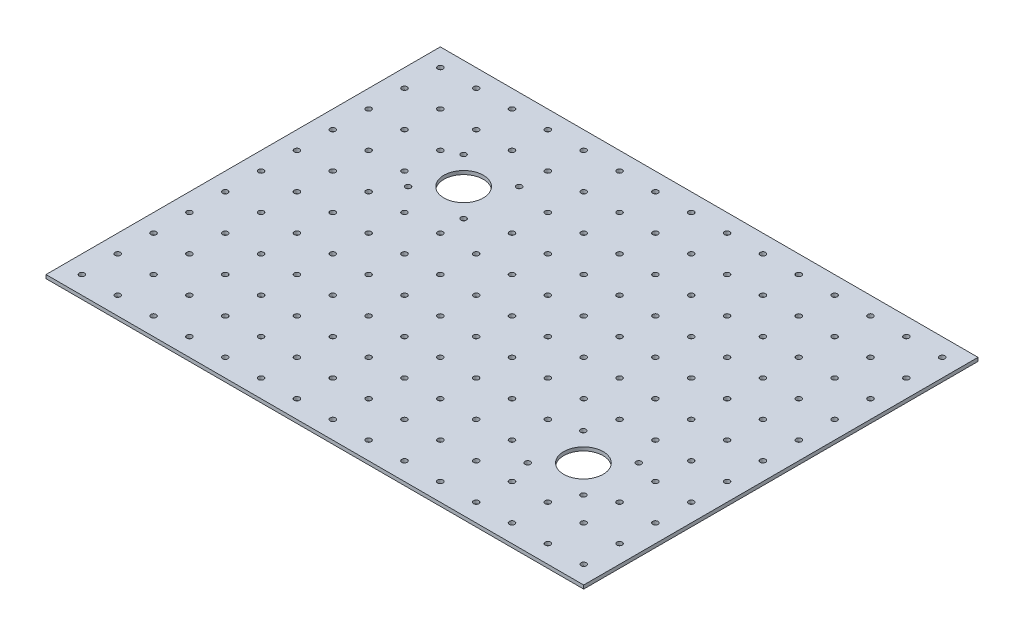
from build123d import *

# Parameters (mm, degrees)
SKETCH1_W           = 220
SKETCH1_H           = 2
BOSS_EXTRUDE1_DEPTH = 300
SKETCH2_R           = 11
SKETCH2_R_2         = 1.5
CUT_EXTRUDE1_DEPTH  = 10


with BuildPart() as part:
    # Sketch1 → Boss-Extrude1 (new body)
    with BuildSketch(Plane(origin=(0, 0, 0), x_dir=(0, 0, -1), z_dir=(1, 0, 0))):
        with Locations((83.3216851, 1)):
            Rectangle(SKETCH1_W, SKETCH1_H)
    extrude(amount=BOSS_EXTRUDE1_DEPTH)

    # Sketch2 → Cut-Extrude1 (cut)
    with BuildSketch(Plane(origin=(0, 2, 0), x_dir=(1, 0, 0), z_dir=(0, 1, 0))):
        with Locations((74, 132.3216851)):
            Circle(SKETCH2_R)
        with Locations((89.5, 116.8216851)):
            Circle(SKETCH2_R_2)
        with Locations((58.5, 116.8216851)):
            Circle(SKETCH2_R_2)
        with Locations((89.5, 147.8216851)):
            Circle(SKETCH2_R_2)
        with Locations((58.5, 147.8216851)):
            Circle(SKETCH2_R_2)
        with Locations((256.33130124, 47.719426297)):
            Circle(SKETCH2_R_2)
        with Locations((256.457517214, 16.719426297)):
            Circle(SKETCH2_R_2)
        with Locations((225.33130124, 16.719426297)):
            Circle(SKETCH2_R_2)
        with Locations((225.33130124, 47.719426297)):
            Circle(SKETCH2_R_2)
        with Locations((240.957517214, 32.219426297)):
            Circle(SKETCH2_R)
        with Locations((10, -16.6783149)):
            Circle(SKETCH2_R_2)
        with Locations((10, 3.3216851)):
            Circle(SKETCH2_R_2)
        with Locations((10, 23.3216851)):
            Circle(SKETCH2_R_2)
        with Locations((10, 63.3216851)):
            Circle(SKETCH2_R_2)
        with Locations((10, 43.3216851)):
            Circle(SKETCH2_R_2)
        with Locations((10, 143.3216851)):
            Circle(SKETCH2_R_2)
        with Locations((10, 123.3216851)):
            Circle(SKETCH2_R_2)
        with Locations((10, 103.3216851)):
            Circle(SKETCH2_R_2)
        with Locations((10, 83.3216851)):
            Circle(SKETCH2_R_2)
        with Locations((10, 183.3216851)):
            Circle(SKETCH2_R_2)
        with Locations((10, 163.3216851)):
            Circle(SKETCH2_R_2)
        with Locations((30, -16.6783149)):
            Circle(SKETCH2_R_2)
        with Locations((30, 3.3216851)):
            Circle(SKETCH2_R_2)
        with Locations((30, 23.3216851)):
            Circle(SKETCH2_R_2)
        with Locations((30, 43.3216851)):
            Circle(SKETCH2_R_2)
        with Locations((30, 63.3216851)):
            Circle(SKETCH2_R_2)
        with Locations((30, 83.3216851)):
            Circle(SKETCH2_R_2)
        with Locations((30, 103.3216851)):
            Circle(SKETCH2_R_2)
        with Locations((30, 123.3216851)):
            Circle(SKETCH2_R_2)
        with Locations((30, 143.3216851)):
            Circle(SKETCH2_R_2)
        with Locations((30, 163.3216851)):
            Circle(SKETCH2_R_2)
        with Locations((30, 183.3216851)):
            Circle(SKETCH2_R_2)
        with Locations((50, -16.6783149)):
            Circle(SKETCH2_R_2)
        with Locations((50, 3.3216851)):
            Circle(SKETCH2_R_2)
        with Locations((50, 23.3216851)):
            Circle(SKETCH2_R_2)
        with Locations((50, 43.3216851)):
            Circle(SKETCH2_R_2)
        with Locations((50, 63.3216851)):
            Circle(SKETCH2_R_2)
        with Locations((50, 83.3216851)):
            Circle(SKETCH2_R_2)
        with Locations((50, 103.3216851)):
            Circle(SKETCH2_R_2)
        with Locations((50, 123.3216851)):
            Circle(SKETCH2_R_2)
        with Locations((50, 143.3216851)):
            Circle(SKETCH2_R_2)
        with Locations((50, 163.3216851)):
            Circle(SKETCH2_R_2)
        with Locations((50, 183.3216851)):
            Circle(SKETCH2_R_2)
        with Locations((70, -16.6783149)):
            Circle(SKETCH2_R_2)
        with Locations((70, 3.3216851)):
            Circle(SKETCH2_R_2)
        with Locations((70, 23.3216851)):
            Circle(SKETCH2_R_2)
        with Locations((70, 43.3216851)):
            Circle(SKETCH2_R_2)
        with Locations((70, 63.3216851)):
            Circle(SKETCH2_R_2)
        with Locations((70, 83.3216851)):
            Circle(SKETCH2_R_2)
        with Locations((70, 103.3216851)):
            Circle(SKETCH2_R_2)
        with Locations((70, 163.3216851)):
            Circle(SKETCH2_R_2)
        with Locations((70, 183.3216851)):
            Circle(SKETCH2_R_2)
        with Locations((90, -16.6783149)):
            Circle(SKETCH2_R_2)
        with Locations((90, 3.3216851)):
            Circle(SKETCH2_R_2)
        with Locations((90, 23.3216851)):
            Circle(SKETCH2_R_2)
        with Locations((90, 43.3216851)):
            Circle(SKETCH2_R_2)
        with Locations((90, 63.3216851)):
            Circle(SKETCH2_R_2)
        with Locations((90, 83.3216851)):
            Circle(SKETCH2_R_2)
        with Locations((90, 103.3216851)):
            Circle(SKETCH2_R_2)
        with Locations((90, 163.3216851)):
            Circle(SKETCH2_R_2)
        with Locations((90, 183.3216851)):
            Circle(SKETCH2_R_2)
        with Locations((110, -16.6783149)):
            Circle(SKETCH2_R_2)
        with Locations((110, 3.3216851)):
            Circle(SKETCH2_R_2)
        with Locations((110, 23.3216851)):
            Circle(SKETCH2_R_2)
        with Locations((110, 43.3216851)):
            Circle(SKETCH2_R_2)
        with Locations((110, 63.3216851)):
            Circle(SKETCH2_R_2)
        with Locations((110, 83.3216851)):
            Circle(SKETCH2_R_2)
        with Locations((110, 103.3216851)):
            Circle(SKETCH2_R_2)
        with Locations((110, 123.3216851)):
            Circle(SKETCH2_R_2)
        with Locations((110, 143.3216851)):
            Circle(SKETCH2_R_2)
        with Locations((110, 163.3216851)):
            Circle(SKETCH2_R_2)
        with Locations((110, 183.3216851)):
            Circle(SKETCH2_R_2)
        with Locations((130, -16.6783149)):
            Circle(SKETCH2_R_2)
        with Locations((130, 3.3216851)):
            Circle(SKETCH2_R_2)
        with Locations((130, 23.3216851)):
            Circle(SKETCH2_R_2)
        with Locations((130, 43.3216851)):
            Circle(SKETCH2_R_2)
        with Locations((130, 63.3216851)):
            Circle(SKETCH2_R_2)
        with Locations((130, 83.3216851)):
            Circle(SKETCH2_R_2)
        with Locations((130, 103.3216851)):
            Circle(SKETCH2_R_2)
        with Locations((130, 123.3216851)):
            Circle(SKETCH2_R_2)
        with Locations((130, 143.3216851)):
            Circle(SKETCH2_R_2)
        with Locations((130, 163.3216851)):
            Circle(SKETCH2_R_2)
        with Locations((130, 183.3216851)):
            Circle(SKETCH2_R_2)
        with Locations((150, -16.6783149)):
            Circle(SKETCH2_R_2)
        with Locations((150, 3.3216851)):
            Circle(SKETCH2_R_2)
        with Locations((150, 23.3216851)):
            Circle(SKETCH2_R_2)
        with Locations((150, 43.3216851)):
            Circle(SKETCH2_R_2)
        with Locations((150, 63.3216851)):
            Circle(SKETCH2_R_2)
        with Locations((150, 83.3216851)):
            Circle(SKETCH2_R_2)
        with Locations((150, 103.3216851)):
            Circle(SKETCH2_R_2)
        with Locations((150, 123.3216851)):
            Circle(SKETCH2_R_2)
        with Locations((150, 143.3216851)):
            Circle(SKETCH2_R_2)
        with Locations((150, 163.3216851)):
            Circle(SKETCH2_R_2)
        with Locations((150, 183.3216851)):
            Circle(SKETCH2_R_2)
        with Locations((170, -16.6783149)):
            Circle(SKETCH2_R_2)
        with Locations((170, 3.3216851)):
            Circle(SKETCH2_R_2)
        with Locations((170, 23.3216851)):
            Circle(SKETCH2_R_2)
        with Locations((170, 43.3216851)):
            Circle(SKETCH2_R_2)
        with Locations((170, 63.3216851)):
            Circle(SKETCH2_R_2)
        with Locations((170, 83.3216851)):
            Circle(SKETCH2_R_2)
        with Locations((170, 103.3216851)):
            Circle(SKETCH2_R_2)
        with Locations((170, 123.3216851)):
            Circle(SKETCH2_R_2)
        with Locations((170, 143.3216851)):
            Circle(SKETCH2_R_2)
        with Locations((170, 163.3216851)):
            Circle(SKETCH2_R_2)
        with Locations((170, 183.3216851)):
            Circle(SKETCH2_R_2)
        with Locations((190, -16.6783149)):
            Circle(SKETCH2_R_2)
        with Locations((190, 3.3216851)):
            Circle(SKETCH2_R_2)
        with Locations((190, 23.3216851)):
            Circle(SKETCH2_R_2)
        with Locations((190, 43.3216851)):
            Circle(SKETCH2_R_2)
        with Locations((190, 63.3216851)):
            Circle(SKETCH2_R_2)
        with Locations((190, 83.3216851)):
            Circle(SKETCH2_R_2)
        with Locations((190, 103.3216851)):
            Circle(SKETCH2_R_2)
        with Locations((190, 123.3216851)):
            Circle(SKETCH2_R_2)
        with Locations((190, 143.3216851)):
            Circle(SKETCH2_R_2)
        with Locations((190, 163.3216851)):
            Circle(SKETCH2_R_2)
        with Locations((190, 183.3216851)):
            Circle(SKETCH2_R_2)
        with Locations((210, -16.6783149)):
            Circle(SKETCH2_R_2)
        with Locations((210, 3.3216851)):
            Circle(SKETCH2_R_2)
        with Locations((210, 23.3216851)):
            Circle(SKETCH2_R_2)
        with Locations((210, 43.3216851)):
            Circle(SKETCH2_R_2)
        with Locations((210, 63.3216851)):
            Circle(SKETCH2_R_2)
        with Locations((210, 83.3216851)):
            Circle(SKETCH2_R_2)
        with Locations((210, 103.3216851)):
            Circle(SKETCH2_R_2)
        with Locations((210, 123.3216851)):
            Circle(SKETCH2_R_2)
        with Locations((210, 143.3216851)):
            Circle(SKETCH2_R_2)
        with Locations((210, 163.3216851)):
            Circle(SKETCH2_R_2)
        with Locations((210, 183.3216851)):
            Circle(SKETCH2_R_2)
        with Locations((230, -16.6783149)):
            Circle(SKETCH2_R_2)
        with Locations((230, 3.3216851)):
            Circle(SKETCH2_R_2)
        with Locations((230, 63.3216851)):
            Circle(SKETCH2_R_2)
        with Locations((230, 83.3216851)):
            Circle(SKETCH2_R_2)
        with Locations((230, 103.3216851)):
            Circle(SKETCH2_R_2)
        with Locations((230, 123.3216851)):
            Circle(SKETCH2_R_2)
        with Locations((230, 143.3216851)):
            Circle(SKETCH2_R_2)
        with Locations((230, 163.3216851)):
            Circle(SKETCH2_R_2)
        with Locations((230, 183.3216851)):
            Circle(SKETCH2_R_2)
        with Locations((250, -16.6783149)):
            Circle(SKETCH2_R_2)
        with Locations((250, 3.3216851)):
            Circle(SKETCH2_R_2)
        with Locations((250, 63.3216851)):
            Circle(SKETCH2_R_2)
        with Locations((250, 83.3216851)):
            Circle(SKETCH2_R_2)
        with Locations((250, 103.3216851)):
            Circle(SKETCH2_R_2)
        with Locations((250, 123.3216851)):
            Circle(SKETCH2_R_2)
        with Locations((250, 143.3216851)):
            Circle(SKETCH2_R_2)
        with Locations((250, 163.3216851)):
            Circle(SKETCH2_R_2)
        with Locations((250, 183.3216851)):
            Circle(SKETCH2_R_2)
        with Locations((270, -16.6783149)):
            Circle(SKETCH2_R_2)
        with Locations((270, 3.3216851)):
            Circle(SKETCH2_R_2)
        with Locations((270, 23.3216851)):
            Circle(SKETCH2_R_2)
        with Locations((270, 43.3216851)):
            Circle(SKETCH2_R_2)
        with Locations((270, 63.3216851)):
            Circle(SKETCH2_R_2)
        with Locations((270, 83.3216851)):
            Circle(SKETCH2_R_2)
        with Locations((270, 103.3216851)):
            Circle(SKETCH2_R_2)
        with Locations((270, 123.3216851)):
            Circle(SKETCH2_R_2)
        with Locations((270, 143.3216851)):
            Circle(SKETCH2_R_2)
        with Locations((270, 163.3216851)):
            Circle(SKETCH2_R_2)
        with Locations((270, 183.3216851)):
            Circle(SKETCH2_R_2)
        with Locations((290, -16.6783149)):
            Circle(SKETCH2_R_2)
        with Locations((290, 3.3216851)):
            Circle(SKETCH2_R_2)
        with Locations((290, 23.3216851)):
            Circle(SKETCH2_R_2)
        with Locations((290, 43.3216851)):
            Circle(SKETCH2_R_2)
        with Locations((290, 63.3216851)):
            Circle(SKETCH2_R_2)
        with Locations((290, 83.3216851)):
            Circle(SKETCH2_R_2)
        with Locations((290, 103.3216851)):
            Circle(SKETCH2_R_2)
        with Locations((290, 123.3216851)):
            Circle(SKETCH2_R_2)
        with Locations((290, 143.3216851)):
            Circle(SKETCH2_R_2)
        with Locations((290, 163.3216851)):
            Circle(SKETCH2_R_2)
        with Locations((290, 183.3216851)):
            Circle(SKETCH2_R_2)
    extrude(amount=-CUT_EXTRUDE1_DEPTH, mode=Mode.SUBTRACT)


solid = part.part
